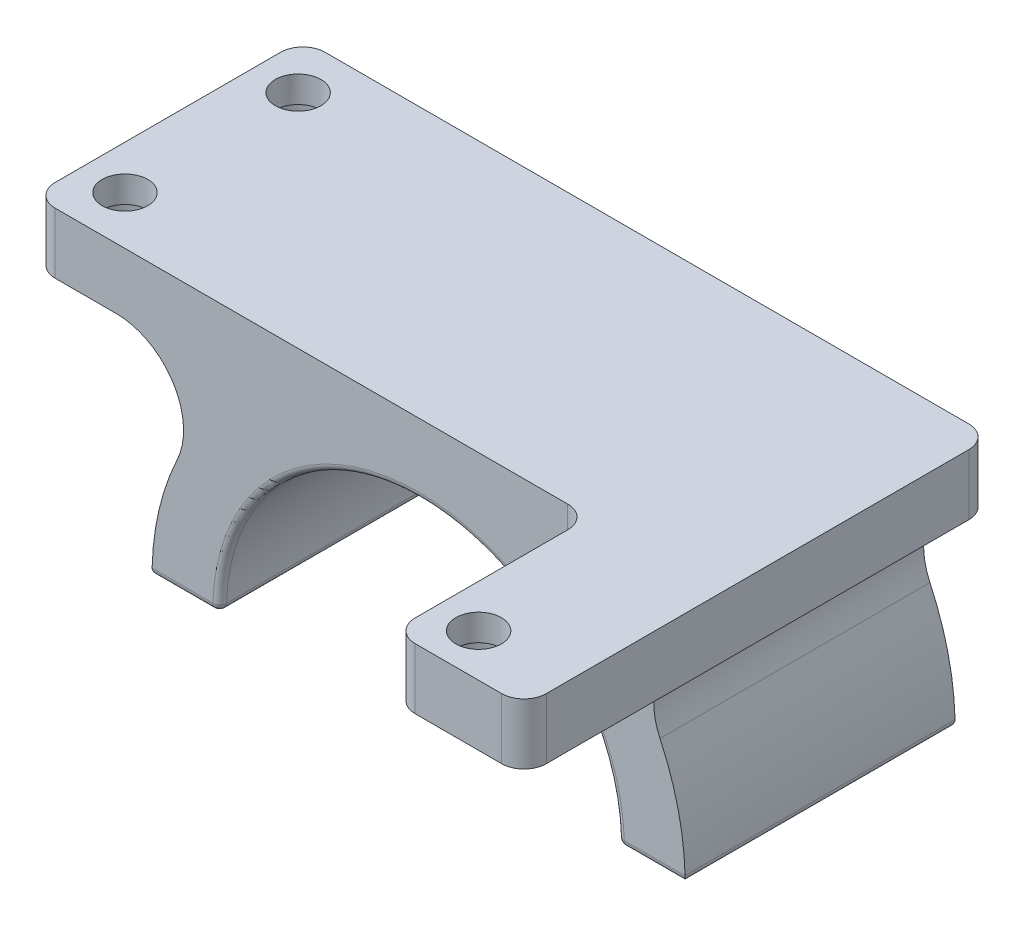
from build123d import *

# Parameters (mm, degrees)
SKETCH1_R           = 39.5
BOSS_EXTRUDE1_DEPTH = 40
CUT_EXTRUDE2_DEPTH  = 41
CUT_EXTRUDE3_DEPTH  = 41
FILLET2_R           = 1
SKETCH6_W           = 114.3
SKETCH6_H           = 9
BOSS_EXTRUDE2_DEPTH = 40
FILLET6_R           = 10
CUT_EXTRUDE4_REACH  = 42
SKETCH9_R           = 3.3782
SKETCH11_W          = 31.75
SKETCH11_H          = 9
BOSS_EXTRUDE3_DEPTH = 29.21
SKETCH4_W           = 3.002871012
SKETCH4_H           = 30
FILLET7_R           = 3.302
SKETCH13_R          = 5.08
CUT_EXTRUDE6_DEPTH  = 5.08
SKETCH15_R          = 3.3782
CUT_EXTRUDE8_DEPTH  = 10
SKETCH16_R          = 5.08
CUT_EXTRUDE9_DEPTH  = 5.08
SKETCH17_W          = 36.586278343
SKETCH17_H          = 70.835632368
CUT_EXTRUDE10_DEPTH = 10
FILLET8_R           = 3.302


with BuildPart() as part:
    # Sketch1 → Boss-Extrude1 (new body)
    with BuildSketch(Plane.XY):
        Circle(SKETCH1_R)
    extrude(amount=BOSS_EXTRUDE1_DEPTH)

    # Sketch2 → Cut-Extrude2 (cut, through all)
    with BuildSketch(Plane(origin=(0, 0, 0), x_dir=(-1, 0, 0), z_dir=(0, 0, -1))):
        with BuildLine():
            Line((-39.5, 0), (39.5, 0))
            ThreePointArc((39.5, 0), (0, -39.5), (-39.5, 0))
        make_face()
    extrude(amount=-CUT_EXTRUDE2_DEPTH, mode=Mode.SUBTRACT)

    # Sketch3 → Cut-Extrude3 (cut, through all)
    with BuildSketch(Plane(origin=(0, 0, 0), x_dir=(-1, 0, 0), z_dir=(0, 0, -1))):
        with BuildLine():
            Line((-29.5, 0), (29.5, 0))
            ThreePointArc((29.5, 0), (0, 29.5), (-29.5, 0))
        make_face()
    extrude(amount=-CUT_EXTRUDE3_DEPTH, mode=Mode.SUBTRACT)

    # Fillet2
    fillet2_edges = [part.edges().sort_by_distance(p)[0] for p in [
        (-34.5, 0, 0),
        (-34.5, 0, 40),
        (0, 29.5, 40),
        (29.5, 0, 20),
        (-29.5, 0, 20),
        (0, 29.5, 0),
        (-39.5, 0, 20),
        (34.5, 0, 0),
        (39.5, 0, 20),
        (34.5, 0, 40),
    ]]
    fillet(fillet2_edges, radius=FILLET2_R)

    # Sketch6 → Boss-Extrude2 (add)
    with BuildSketch(Plane(origin=(0, 0, 0), x_dir=(-1, 0, 0), z_dir=(0, 0, -1))):
        with Locations((0, 35.5)):
            Rectangle(SKETCH6_W, SKETCH6_H)
    extrude(amount=-BOSS_EXTRUDE2_DEPTH)

    # Fillet6
    fillet6_edges = [part.edges().sort_by_distance(p)[0] for p in [
        (-24.47958333, 31, 20),
        (24.47958333, 31, 20),
    ]]
    fillet(fillet6_edges, radius=FILLET6_R)

    # Sketch9 → Cut-Extrude4 (cut, up to next)
    with BuildSketch(Plane(origin=(0, 40, 0), x_dir=(1, 0, 0), z_dir=(0, 1, 0)), mode=Mode.PRIVATE) as cut_extrude4_sk1:
        with Locations((-50.677371465, -7.173)):
            Circle(SKETCH9_R)
    cut_extrude4_tool1 = extrude(cut_extrude4_sk1.sketch, amount=-CUT_EXTRUDE4_REACH, mode=Mode.PRIVATE) & part.part
    add(cut_extrude4_tool1.solids().sort_by_distance((-50.677371, 40, 7.173))[0], mode=Mode.SUBTRACT)
    # Sketch9 → Cut-Extrude4 (cut, up to next)
    with BuildSketch(Plane(origin=(0, 40, 0), x_dir=(1, 0, 0), z_dir=(0, 1, 0)), mode=Mode.PRIVATE) as cut_extrude4_sk2:
        with Locations((-50.677371465, -32.827)):
            Circle(SKETCH9_R)
    cut_extrude4_tool2 = extrude(cut_extrude4_sk2.sketch, amount=-CUT_EXTRUDE4_REACH, mode=Mode.PRIVATE) & part.part
    add(cut_extrude4_tool2.solids().sort_by_distance((-50.677371, 40, 32.827))[0], mode=Mode.SUBTRACT)

    # Sketch11 → Boss-Extrude3 (add)
    with BuildSketch(Plane.XY.offset(40)):
        with Locations((41.275, 35.5)):
            Rectangle(SKETCH11_W, SKETCH11_H)
    extrude(amount=BOSS_EXTRUDE3_DEPTH)

    # Sketch4 → Cut-Revolve1 (revolve, cut)
    with BuildSketch(Plane.XZ):
        with Locations((34.48557529, 20)):
            Rectangle(SKETCH4_W, SKETCH4_H)
    revolve(axis=Axis((0, 0, 0), (0, 0, 1)), mode=Mode.SUBTRACT)

    # Fillet7
    fillet7_edges = [part.edges().sort_by_distance(p)[0] for p in [
        (25.4, 35.5, 40),
        (25.4, 35.5, 69.21),
        (57.15, 35.5, 69.21),
        (-57.15, 35.5, 0),
        (57.15, 35.5, 0),
        (-57.15, 35.5, 40),
    ]]
    fillet(fillet7_edges, radius=FILLET7_R)

    # Sketch13 → Cut-Extrude6 (cut)
    with BuildSketch(Plane.XZ.offset(-31)):
        with Locations((-50.677371465, 32.827)):
            Circle(SKETCH13_R)
        with Locations((-50.677371465, 7.173)):
            Circle(SKETCH13_R)
    extrude(amount=-CUT_EXTRUDE6_DEPTH, mode=Mode.SUBTRACT)

    # Sketch15 → Cut-Extrude8 (cut, through all)
    with BuildSketch(Plane.XZ.offset(-31)):
        with Locations((31.75, 62.86)):
            Circle(SKETCH15_R)
    extrude(amount=-CUT_EXTRUDE8_DEPTH, mode=Mode.SUBTRACT)

    # Sketch16 → Cut-Extrude9 (cut)
    with BuildSketch(Plane.XZ.offset(-31)):
        with Locations((31.75, 62.86)):
            Circle(SKETCH16_R)
    extrude(amount=-CUT_EXTRUDE9_DEPTH, mode=Mode.SUBTRACT)

    # Sketch17 → Cut-Extrude10 (cut, through all)
    with BuildSketch(Plane.XZ.offset(-31)):
        with Locations((63.117797564, 35.417816184)):
            Rectangle(SKETCH17_W, SKETCH17_H)
    extrude(amount=-CUT_EXTRUDE10_DEPTH, mode=Mode.SUBTRACT)

    # Fillet8
    fillet8_edges = [part.edges().sort_by_distance(p)[0] for p in [
        (44.824658392, 35.5, 69.21),
        (44.824658392, 35.5, 0),
    ]]
    fillet(fillet8_edges, radius=FILLET8_R)


with BuildPart() as body_2:
    # Mirror8: mirrored copy
    add(part.part.mirror(Plane(origin=(-57.15, 40, 154.653783191), x_dir=(0, 0, 1), z_dir=(-1, 0, 0))))


solid = part.part
